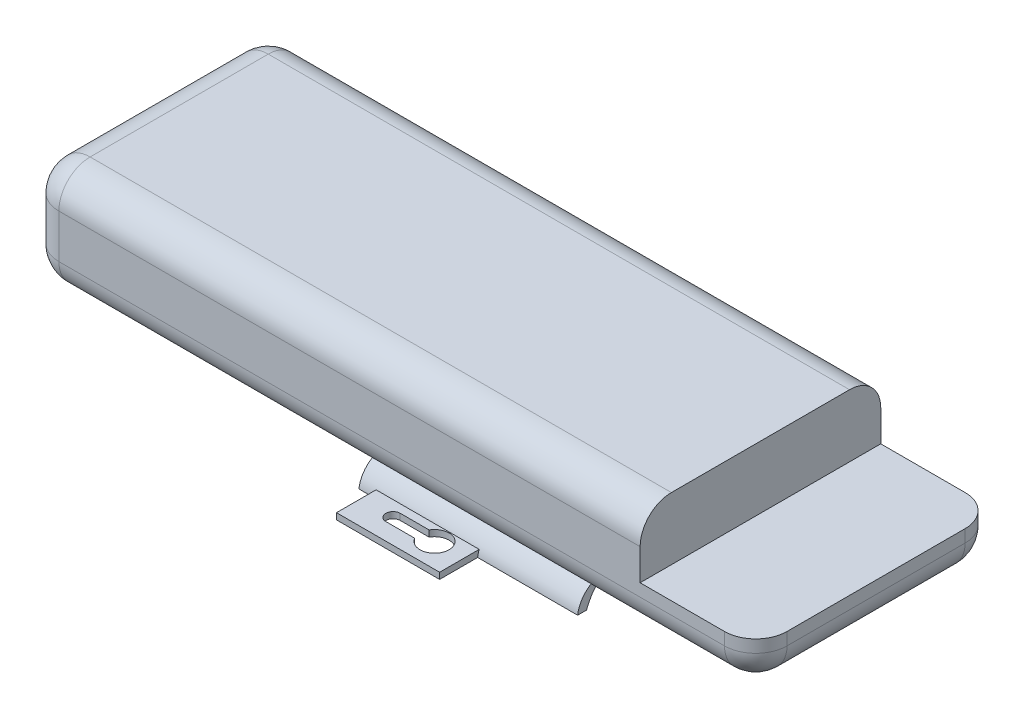
from build123d import *

# Parameters (mm, degrees)
SKETCH_1_W          = 233
SKETCH_1_H          = 77
EXTRUDE_1_DEPTH     = 34
FILLET_1_R          = 10
EXTRUDE_START       = -77
EXTRUDE_2_DEPTH     = 70
SKETCH_5_W          = 59.720713377
SKETCH_5_H          = 124.634532265
CUT_EXTRUDE_1_DEPTH = 20
SKETCH_6_W          = 33
SKETCH_6_H          = 15
EXTRUDE_3_DEPTH     = 2
CUT_EXTRUDE_2_DEPTH = 2


with BuildPart() as part:
    # 草图1 → 凸台-拉伸1 (new body)
    with BuildSketch(Plane(origin=(0, 0, 0), x_dir=(1, 0, 0), z_dir=(0, 1, 0))):
        Rectangle(SKETCH_1_W, SKETCH_1_H)
    extrude(amount=EXTRUDE_1_DEPTH)

    # 圆角1
    fillet_1_edges = [part.edges().sort_by_distance(p)[0] for p in [
        (-116.5, 34, 0),
        (0, 34, 38.5),
        (116.5, 34, 0),
        (0, 0, 38.5),
        (-116.5, 0, 0),
        (0, 0, -38.5),
        (116.5, 0, 0),
        (0, 34, -38.5),
        (116.5, 17, 38.5),
        (-116.5, 17, 38.5),
        (-116.5, 17, -38.5),
        (116.5, 17, -38.5),
    ]]
    fillet(fillet_1_edges, radius=FILLET_1_R)

    # 草图4 → 凸台-拉伸2 (add)
    with BuildSketch(Plane(origin=(116.5, 0, 0), x_dir=(0, 0, -1), z_dir=(1, 0, 0)).offset(EXTRUDE_START)):
        with BuildLine():
            Line((0, 0), (18.5, 0))
            Line((18.5, 0), (18.5, -1.572066466))
            ThreePointArc((18.5, -1.572066466), (9.800777778, -8.264788257), (14.039660918, -18.389059192))
            ThreePointArc((14.039660918, -18.389059192), (17.041590901, -21.173830143), (18.5, -25))
            Line((18.5, -25), (15.661233875, -25))
            ThreePointArc((15.661233875, -25), (9.569146337, -17.024771316), (0, -14))
            Line((0, -14), (0, 0))
        make_face()
    extrude_2 = extrude(amount=-EXTRUDE_2_DEPTH)

    # 草图5 → 切除-拉伸1 (cut)
    with BuildSketch(Plane(origin=(0, 34, 0), x_dir=(1, 0, 0), z_dir=(0, 1, 0))):
        with Locations((109.360356689, 0.216379396)):
            Rectangle(SKETCH_5_W, SKETCH_5_H)
    extrude(amount=-CUT_EXTRUDE_1_DEPTH, mode=Mode.SUBTRACT)

    # 镜向1: 凸台-拉伸2 across plane
    add(extrude_2.mirror(Plane(origin=(-30.5, 0, 0), x_dir=(1, 0, 0), z_dir=(0, 0, 1))))

    # 草图6 → 凸台-拉伸3 (add)
    with BuildSketch(Plane.XZ.offset(25)):
        with Locations((-9, 23.161233875)):
            Rectangle(SKETCH_6_W, SKETCH_6_H)
    extrude_3 = extrude(amount=-EXTRUDE_3_DEPTH)

    # 草图7 → 切除-拉伸2 (cut)
    with BuildSketch(Plane(origin=(0, -25, 0), x_dir=(-1, 0, 0), z_dir=(0, -1, 0))):
        with BuildLine():
            Line((5.906379753, -20.624259192), (15.136057616, -20.624259192))
            ThreePointArc((15.136057616, -20.624259192), (17.436057616, -22.924259192), (15.136057616, -25.224259192))
            Line((15.136057616, -25.224259192), (5.906379753, -25.224259192))
            ThreePointArc((5.906379753, -25.224259192), (-2.784969032, -22.924259192), (5.906379753, -20.624259192))
        make_face()
    cut_extrude_2 = extrude(amount=-CUT_EXTRUDE_2_DEPTH, mode=Mode.SUBTRACT)

    # 镜向2: 凸台-拉伸3, 切除-拉伸2 across plane
    add(extrude_3.mirror(Plane.XY))
    add(cut_extrude_2.mirror(Plane.XY), mode=Mode.SUBTRACT)


solid = part.part
